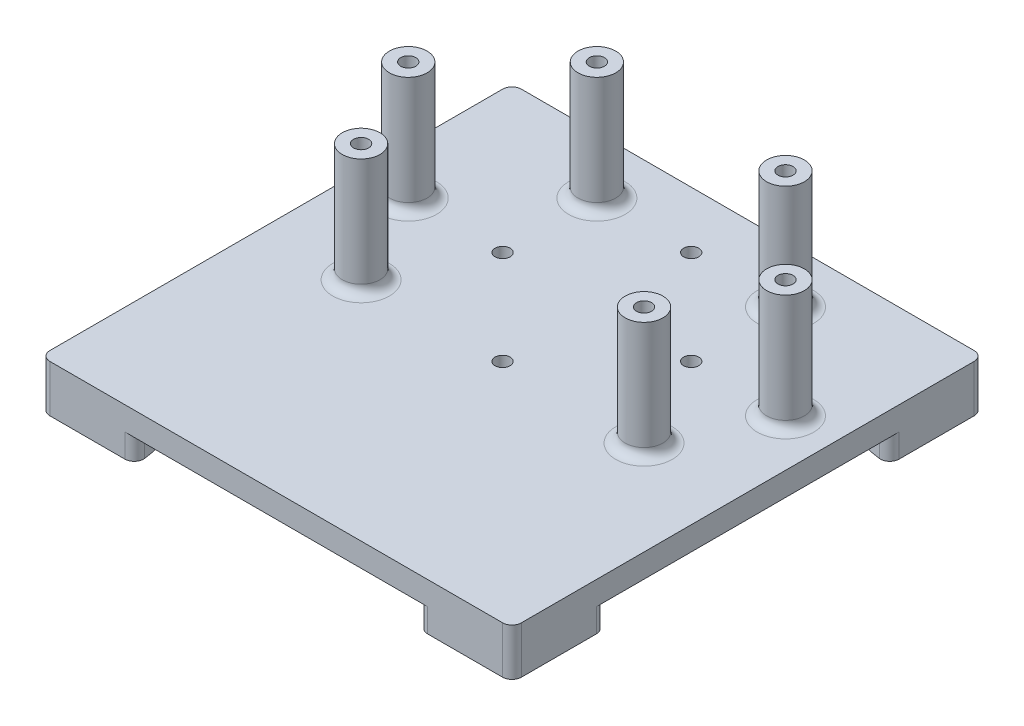
from build123d import *

# Parameters (mm, degrees)
SKETCH_1_W          = 100
SKETCH_1_H          = 100
EXTRUDE_1_DEPTH     = 5
SKETCH_5_R          = 4
SKETCH_5_R_2        = 1.6
EXTRUDE_2_DEPTH     = 25
SKETCH_6_R          = 1.6
CUT_EXTRUDE_1_DEPTH = 5
EXTRUDE_3_DEPTH     = 5
FILLET_1_R          = 2


with BuildPart() as part:
    # 草图1 → 凸台-拉伸1 (new body)
    with BuildSketch(Plane(origin=(57, 0, 0), x_dir=(1, 0, 0), z_dir=(0, 1, 0))):
        Rectangle(SKETCH_1_W, SKETCH_1_H)
    extrude(amount=EXTRUDE_1_DEPTH)

    # 草图5 → 凸台-拉伸2 (add)
    with BuildSketch(Plane(origin=(0, 5, 0), x_dir=(1, 0, 0), z_dir=(0, 1, 0))):
        with Locations((77, 38)):
            Circle(SKETCH_5_R)
        with Locations((77, 38)):
            Circle(SKETCH_5_R_2, mode=Mode.SUBTRACT)
        with Locations((97, 18)):
            Circle(SKETCH_5_R)
        with Locations((97, 18)):
            Circle(SKETCH_5_R_2, mode=Mode.SUBTRACT)
        with Locations((87, -2)):
            Circle(SKETCH_5_R)
        with Locations((87, -2)):
            Circle(SKETCH_5_R_2, mode=Mode.SUBTRACT)
        with Locations((27, -2)):
            Circle(SKETCH_5_R)
        with Locations((27, -2)):
            Circle(SKETCH_5_R_2, mode=Mode.SUBTRACT)
        with Locations((17, 18)):
            Circle(SKETCH_5_R)
        with Locations((17, 18)):
            Circle(SKETCH_5_R_2, mode=Mode.SUBTRACT)
        with Locations((37, 38)):
            Circle(SKETCH_5_R)
        with Locations((37, 38)):
            Circle(SKETCH_5_R_2, mode=Mode.SUBTRACT)
    extrude(amount=EXTRUDE_2_DEPTH)

    # 草图6 → 切除-拉伸1 (cut)
    with BuildSketch(Plane(origin=(0, 5, 0), x_dir=(1, 0, 0), z_dir=(0, 1, 0))):
        with Locations((57, 38)):
            Circle(SKETCH_6_R)
        with Locations((37, 18)):
            Circle(SKETCH_6_R)
        with Locations((77, 18)):
            Circle(SKETCH_6_R)
        with Locations((57, -2)):
            Circle(SKETCH_6_R)
    extrude(amount=-CUT_EXTRUDE_1_DEPTH, mode=Mode.SUBTRACT)

    # 草图7 → 凸台-拉伸3 (add)
    with BuildSketch(Plane.XZ):
        with BuildLine():
            Line((27, 50), (7, 50))
            Line((7, 50), (7, 30))
            ThreePointArc((7, 30), (21.142135624, 35.857864376), (27, 50))
        make_face()
        with BuildLine():
            ThreePointArc((27, -50), (21.142135624, -35.857864376), (7, -30))
            Line((7, -30), (7, -50))
            Line((7, -50), (27, -50))
        make_face()
        with BuildLine():
            Line((107, -50), (107, -30))
            ThreePointArc((107, -30), (92.857864376, -35.857864376), (87, -50))
            Line((87, -50), (107, -50))
        make_face()
        with BuildLine():
            Line((107, 50), (107, 30))
            ThreePointArc((107, 30), (92.857864376, 35.857864376), (87, 50))
            Line((87, 50), (107, 50))
        make_face()
    extrude(amount=EXTRUDE_3_DEPTH)

    # 圆角1
    fillet_1_edges = [part.edges().sort_by_distance(p)[0] for p in [
        (107, -2.5, -30),
        (87, -2.5, -50),
        (87, -2.5, 50),
        (107, -2.5, 30),
        (73, 5, -38),
        (93, 5, -18),
        (83, 5, 2),
        (23, 5, 2),
        (13, 5, -18),
        (33, 5, -38),
        (107, 0, 50),
        (7, 0, 50),
        (7, 0, -50),
        (107, 0, -50),
        (7, -2.5, 30),
        (27, -2.5, 50),
        (27, -2.5, -50),
        (7, -2.5, -30),
    ]]
    fillet(fillet_1_edges, radius=FILLET_1_R)


solid = part.part
